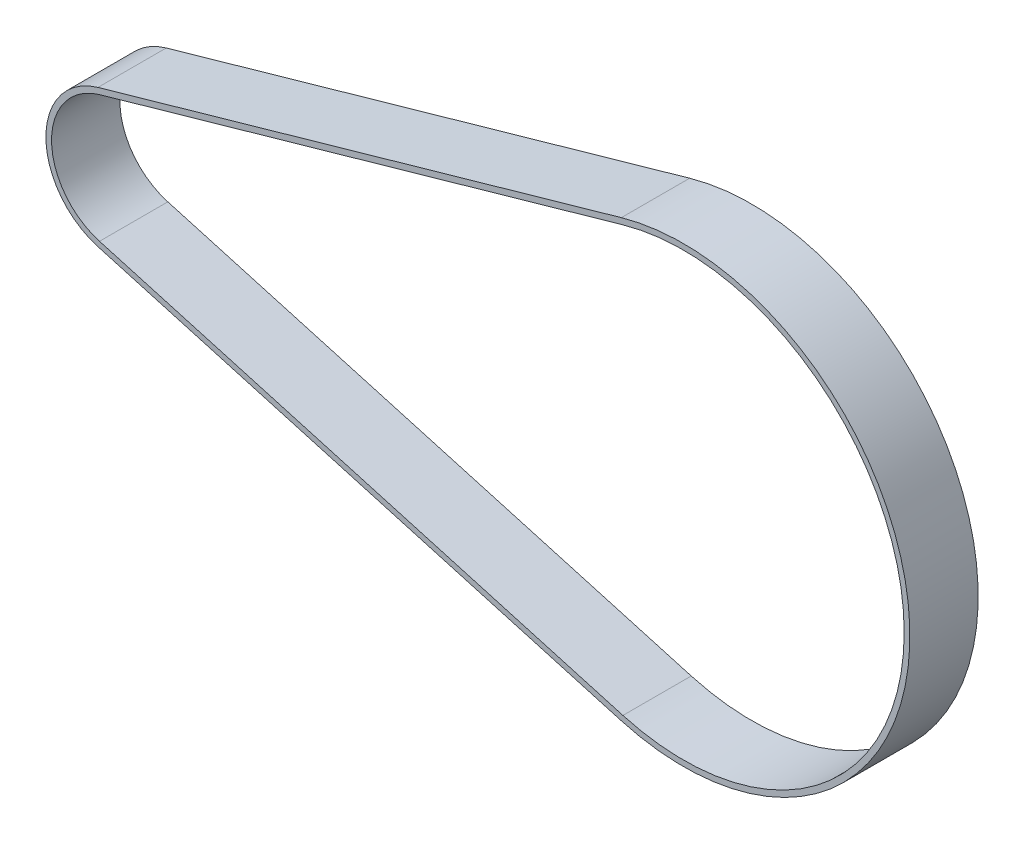
from build123d import *

# Parameters (mm, degrees)
BOSS_EXTRUDE1_DEPTH = 6


with BuildPart() as part:
    # Sketch1 → Boss-Extrude1 (new body)
    with BuildSketch(Plane.XY):
        with BuildLine():
            Line((-1.723943662, 6.059539442), (44.254527163, 19.140449984))
            ThreePointArc((44.254527163, 19.140449984), (69.6, 0), (44.254527163, -19.140449984))
            Line((44.254527163, -19.140449984), (-1.723943662, -6.059539442))
            ThreePointArc((-1.723943662, -6.059539442), (-6.3, 0), (-1.723943662, 6.059539442))
        make_face()
        with BuildLine():
            Line((-1.587122736, 5.578623613), (44.391348089, 18.659534155))
            ThreePointArc((44.391348089, 18.659534155), (69.1, 0), (44.391348089, -18.659534155))
            Line((44.391348089, -18.659534155), (-1.587122736, -5.578623613))
            ThreePointArc((-1.587122736, -5.578623613), (-5.8, 0), (-1.587122736, 5.578623613))
        make_face(mode=Mode.SUBTRACT)
    extrude(amount=BOSS_EXTRUDE1_DEPTH)


solid = part.part
